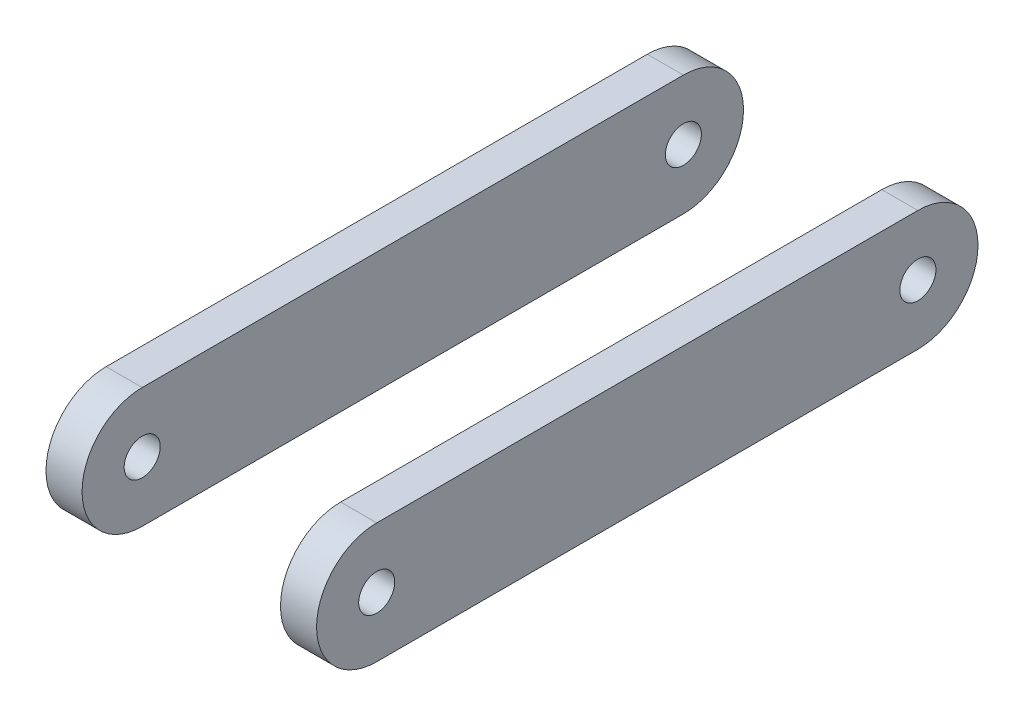
from build123d import *

# Parameters (mm, degrees)
BOSS_EXTRUDE1_DEPTH     = 6
CUT_EXTRUDE1_DEPTH      = 101.677703589
CUT_EXTRUDE1_DEPTH_BACK = 101.677703589
SKETCH2_R               = 3


with BuildPart() as part:
    # Sketch1 → Boss-Extrude1 (new body)
    with BuildSketch(Plane(origin=(16.5, 0, 0), x_dir=(0, 0, -1), z_dir=(1, 0, 0))):
        with BuildLine():
            Line((0, 10), (90, 10))
            ThreePointArc((90, 10), (100, 0), (90, -10))
            Line((90, -10), (0, -10))
            ThreePointArc((0, -10), (-10, 0), (0, 10))
        make_face()
    extrude(amount=BOSS_EXTRUDE1_DEPTH)

    # Sketch2 → Cut-Extrude1 (cut, two sides: drawn at the far end of the back side and taken through both)
    with BuildSketch(Plane(origin=(22.5, 0, 0), x_dir=(0, 0, -1), z_dir=(1, 0, 0)).offset(-CUT_EXTRUDE1_DEPTH_BACK)):
        Circle(SKETCH2_R)
        with Locations((90, 0)):
            Circle(SKETCH2_R)
    extrude(amount=CUT_EXTRUDE1_DEPTH + CUT_EXTRUDE1_DEPTH_BACK, mode=Mode.SUBTRACT)


with BuildPart() as body_2:
    # Mirror4: mirrored copy
    add(part.part.mirror(Plane(origin=(0, 0, 0), x_dir=(0, 0, 1), z_dir=(1, 0, 0))))


solid = Compound([part.part, body_2.part])
